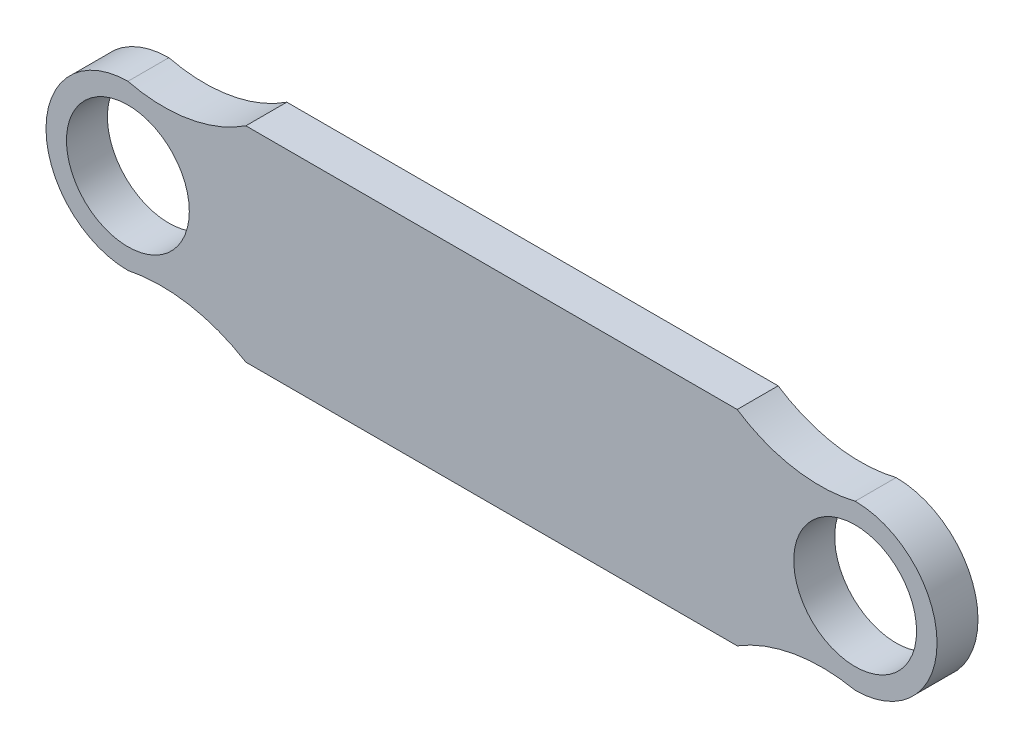
from build123d import *

# Parameters (mm, degrees)
SKETCH1_R           = 4.5
BOSS_EXTRUDE1_DEPTH = 3


with BuildPart() as part:
    # Sketch1 → Boss-Extrude1 (new body)
    with BuildSketch(Plane.XY):
        with BuildLine():
            ThreePointArc((-25.027731338, -5.77818799), (-21.380140782, -6.093283782), (-18, -7.5))
            Line((-18, -7.5), (18, -7.5))
            ThreePointArc((18, -7.5), (21.380140782, -6.093283782), (25.027731338, -5.77818799))
            ThreePointArc((25.027731338, -5.77818799), (25.839696877, -5.861423129), (26.644067797, -6))
            ThreePointArc((26.644067797, -6), (32.644067797, 0), (26.644067797, 6))
            ThreePointArc((26.644067797, 6), (25.734720833, 5.818198735), (24.813267337, 5.713857688))
            ThreePointArc((24.813267337, 5.713857688), (21.259366627, 6.045176449), (18, 7.5))
            Line((18, 7.5), (-18, 7.5))
            ThreePointArc((-18, 7.5), (-21.259366627, 6.045176449), (-24.813267337, 5.713857688))
            ThreePointArc((-24.813267337, 5.713857688), (-25.734720833, 5.818198735), (-26.644067797, 6))
            ThreePointArc((-26.644067797, 6), (-32.644067797, 0), (-26.644067797, -6))
            ThreePointArc((-26.644067797, -6), (-25.839696877, -5.861423129), (-25.027731338, -5.77818799))
        make_face()
        with Locations((-26.644067797, 0)):
            Circle(SKETCH1_R, mode=Mode.SUBTRACT)
        with Locations((26.644067797, 0)):
            Circle(SKETCH1_R, mode=Mode.SUBTRACT)
    extrude(amount=BOSS_EXTRUDE1_DEPTH)


solid = part.part
